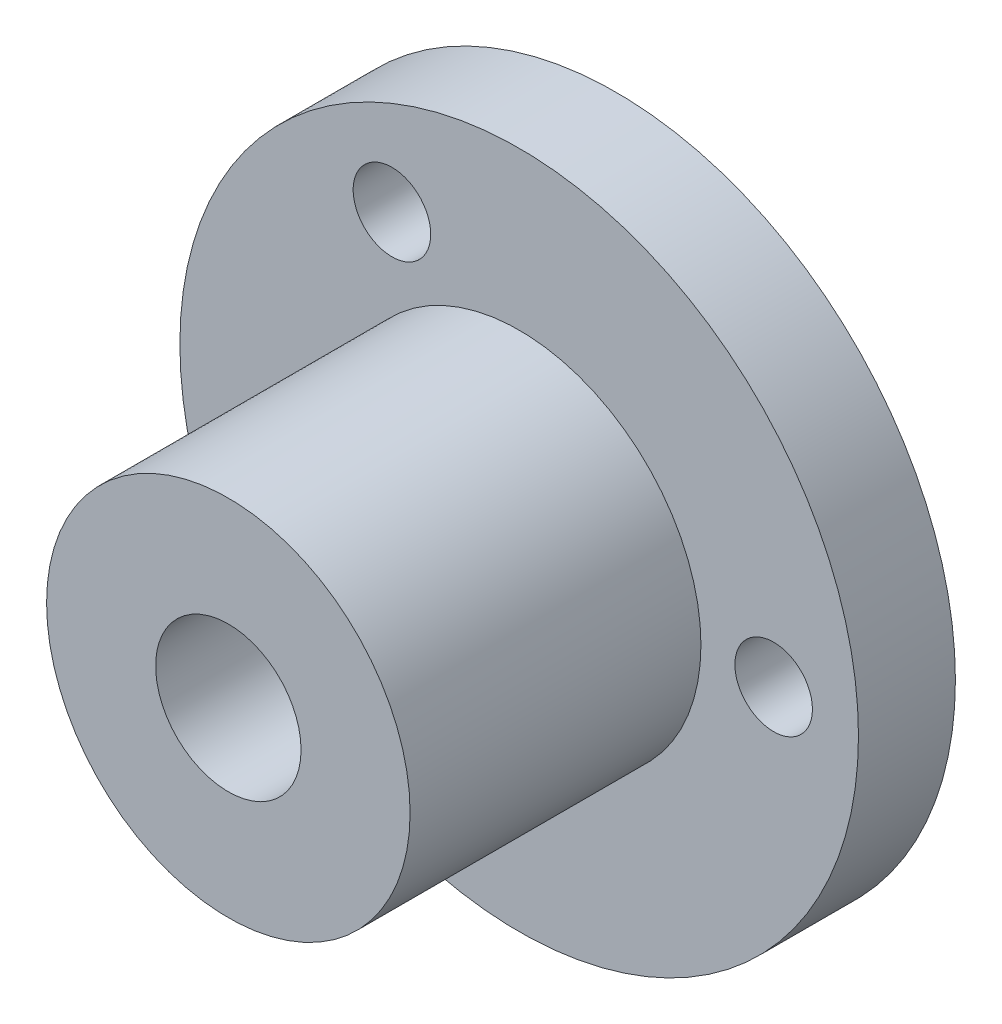
from build123d import *

# Parameters (mm, degrees)
SKETCH_1_R      = 14
SKETCH_1_R_2    = 1.6
SKETCH_1_R_3    = 3
EXTRUDE_2_DEPTH = 4
SKETCH_2_R      = 7.5
SKETCH_2_R_2    = 3
EXTRUDE_3_DEPTH = 12


with BuildPart() as part:
    # ｽｹｯﾁ1 → ﾎﾞｽ - 押し出し2 (new body)
    with BuildSketch(Plane.XY):
        Circle(SKETCH_1_R)
        with Locations((10.5, 0)):
            Circle(SKETCH_1_R_2, mode=Mode.SUBTRACT)
        with Locations((-5.25, 9.09326674)):
            Circle(SKETCH_1_R_2, mode=Mode.SUBTRACT)
        with Locations((-5.25, -9.09326674)):
            Circle(SKETCH_1_R_2, mode=Mode.SUBTRACT)
        Circle(SKETCH_1_R_3, mode=Mode.SUBTRACT)
    extrude(amount=EXTRUDE_2_DEPTH)

    # ｽｹｯﾁ2 → ﾎﾞｽ - 押し出し3 (add)
    with BuildSketch(Plane.XY.offset(4)):
        Circle(SKETCH_2_R)
        Circle(SKETCH_2_R_2, mode=Mode.SUBTRACT)
    extrude(amount=EXTRUDE_3_DEPTH)


solid = part.part
